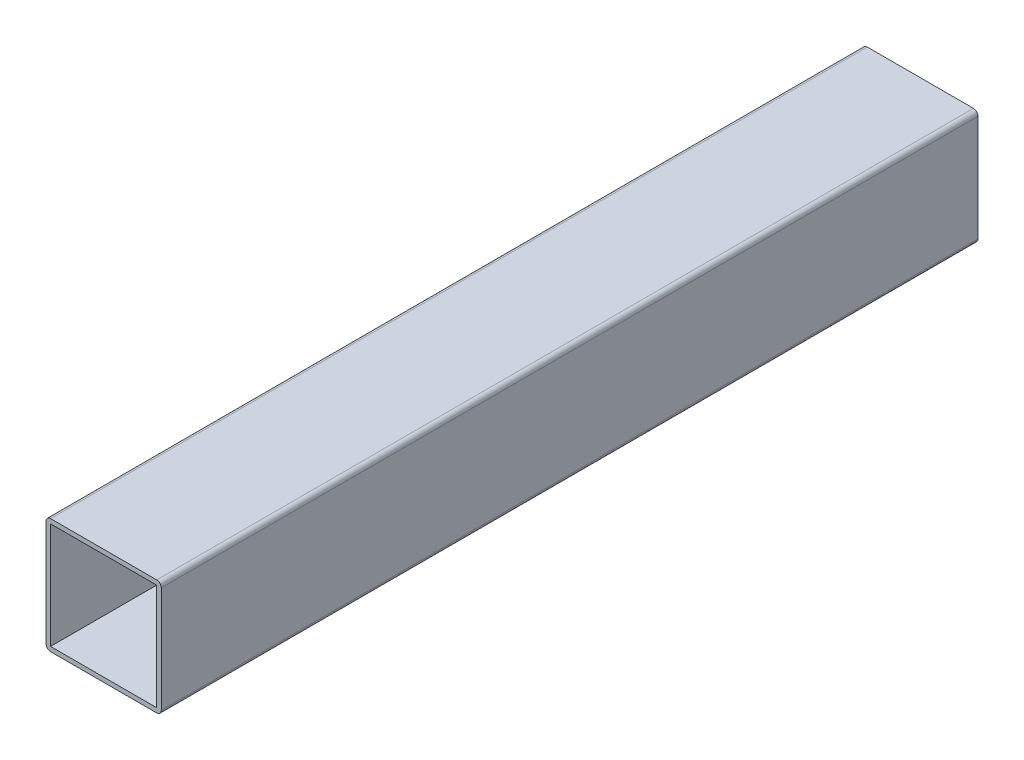
from build123d import *

# Parameters (mm, degrees)
CROQUIS1_W              = 23.4
CROQUIS1_H              = 23.4
SALIENTE_EXTRUIR1_DEPTH = 180


with BuildPart() as part:
    # Croquis1 → Saliente-Extruir1 (new body)
    with BuildSketch(Plane.XY):
        with BuildLine():
            Line((-11.7, -12.7), (11.7, -12.7))
            ThreePointArc((11.7, -12.7), (12.407106781, -12.407106781), (12.7, -11.7))
            Line((12.7, -11.7), (12.7, 11.7))
            ThreePointArc((12.7, 11.7), (12.407106781, 12.407106781), (11.7, 12.7))
            Line((11.7, 12.7), (-11.7, 12.7))
            ThreePointArc((-11.7, 12.7), (-12.407106781, 12.407106781), (-12.7, 11.7))
            Line((-12.7, 11.7), (-12.7, -11.7))
            ThreePointArc((-12.7, -11.7), (-12.407106781, -12.407106781), (-11.7, -12.7))
        make_face()
        Rectangle(CROQUIS1_W, CROQUIS1_H, mode=Mode.SUBTRACT)
    extrude(amount=-SALIENTE_EXTRUIR1_DEPTH)


solid = part.part
